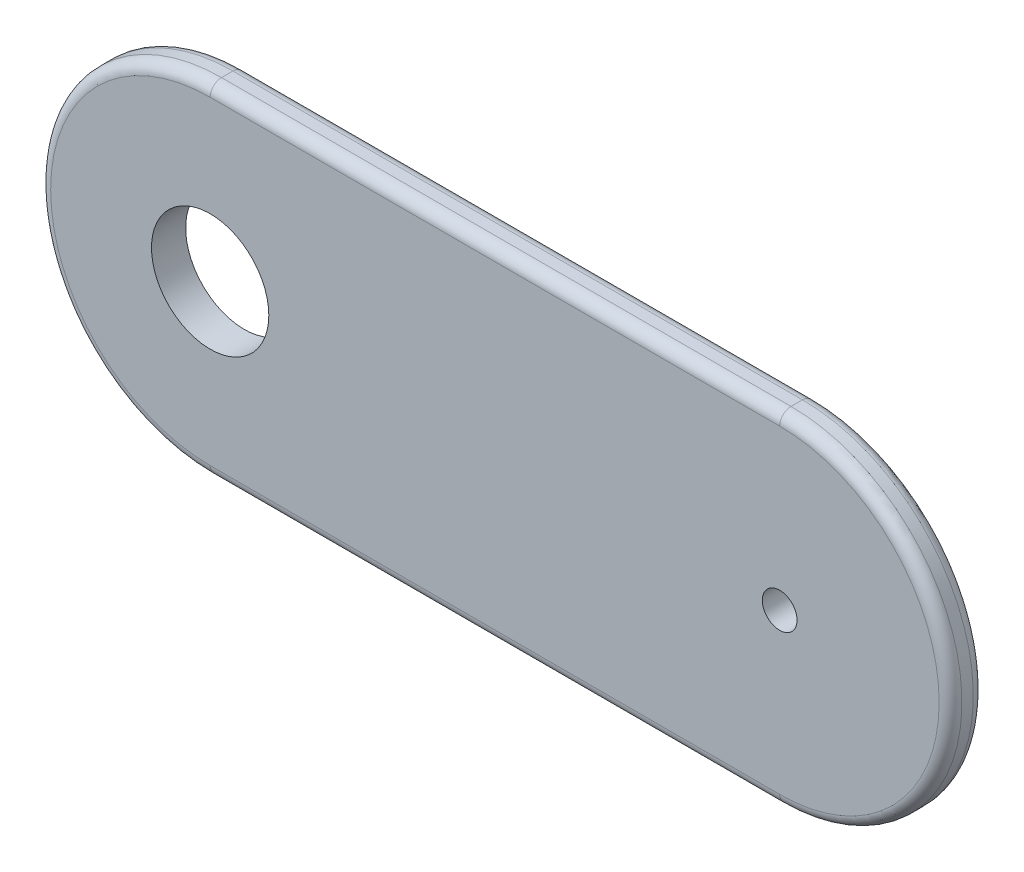
from build123d import *

# Parameters (mm, degrees)
EXTRUDE_1_DEPTH     = 3
SKETCH_1_3_R        = 1.525
CUT_EXTRUDE_1_DEPTH = 5
FILLET_1_R          = 1
SKETCH_2_R          = 5.15
CUT_EXTRUDE_2_DEPTH = 5


with BuildPart() as part:
    # 草图1 → 凸台-拉伸1 (new body)
    with BuildSketch(Plane.XY):
        with BuildLine():
            Line((0, 15), (50, 15))
            ThreePointArc((50, 15), (65, 0), (50, -15))
            Line((50, -15), (0, -15))
            ThreePointArc((0, -15), (-15, 0), (0, 15))
        make_face()
    extrude(amount=EXTRUDE_1_DEPTH)

    # 草图1<3> → 切除-拉伸1 (cut)
    with BuildSketch(Plane.XY):
        with Locations((50, 0)):
            Circle(SKETCH_1_3_R)
    extrude(amount=CUT_EXTRUDE_1_DEPTH, mode=Mode.SUBTRACT)

    # 圆角1
    fillet_1_edges = [part.edges().sort_by_distance(p)[0] for p in [
        (-15, 0, 0),
        (25, -15, 0),
        (65, 0, 0),
        (-15, 0, 3),
        (25, -15, 3),
        (65, 0, 3),
        (25, 15, 0),
        (25, 15, 3),
    ]]
    fillet(fillet_1_edges, radius=FILLET_1_R)

    # 草图2 → 切除-拉伸2 (cut)
    with BuildSketch(Plane.XY.offset(3)):
        Circle(SKETCH_2_R)
    extrude(amount=-CUT_EXTRUDE_2_DEPTH, mode=Mode.SUBTRACT)


solid = part.part
